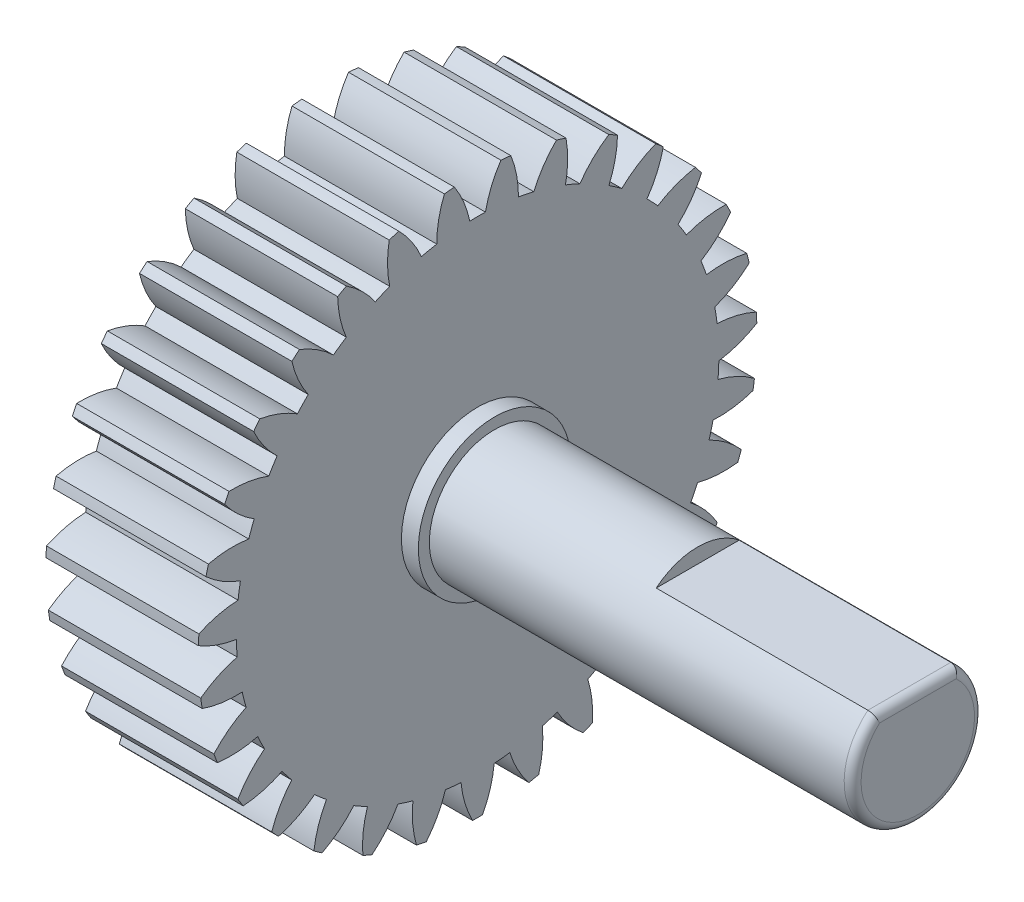
from build123d import *

# Parameters (mm, degrees)
BASPROSKE_W              = 9
BASPROSKE_H              = 16.5
TOOTHCUT_DEPTH           = 26.009998001
TEETHCUTS_COUNT          = 31
TEETHCUTS_ANGLE          = 348.387096774
BORSKE_R                 = 2
BORE_DEPTH               = 50.0000508
SKETCH2_R                = 4.5
BOSS_EXTRUDE1_DEPTH      = 1
BOSS_EXTRUDE2_DEPTH      = 26
BOSS_EXTRUDE2_DEPTH_BACK = 9
BOSS_EXTRUDE3_DEPTH      = 13
BOSS_EXTRUDE3_DEPTH_BACK = 9
FILLET1_R                = 0.5


with BuildPart() as part:
    # BasProSke → Base-Revolve (revolve)
    with BuildSketch(Plane(origin=(0, 0, 0), x_dir=(1, 0, 0), z_dir=(0, 1, 0))):
        with Locations((4.5, 8.25)):
            Rectangle(BASPROSKE_W, BASPROSKE_H)
    revolve(axis=Axis((-10, 0, 0), (1, 0, 0)))

    # TooCutSke → ToothCut (cut, through all)
    with BuildSketch(Plane(origin=(0, 0, 0), x_dir=(0, 0, -1), z_dir=(1, 0, 0))):
        with BuildLine():
            ThreePointArc((0.464153838, 14.241438207), (0, 14.249), (-0.464153838, 14.241438207))
            ThreePointArc((-0.464153838, 14.241438207), (-0.818831014, 15.399587018), (-1.391915479, 16.466675938))
            ThreePointArc((-1.391915479, 16.466675938), (0, 16.5254), (1.391915479, 16.466675938))
            ThreePointArc((1.391915479, 16.466675938), (0.818831014, 15.399587018), (0.464153838, 14.241438207))
        make_face()
    toothcut = extrude(amount=TOOTHCUT_DEPTH, mode=Mode.SUBTRACT)

    # TeethCuts: ToothCut ×31 about axis
    teethcuts_axis = Axis((-10, 0, 0), (1, 0, 0))
    for i in range(1, TEETHCUTS_COUNT):
        add(toothcut.rotate(teethcuts_axis, i * TEETHCUTS_ANGLE / (TEETHCUTS_COUNT - 1)), mode=Mode.SUBTRACT)

    # BorSke → Bore (cut, symmetric)
    with BuildSketch(Plane(origin=(0, 0, 0), x_dir=(0, 0, -1), z_dir=(1, 0, 0))):
        Circle(BORSKE_R)
    extrude(amount=BORE_DEPTH, both=True, mode=Mode.SUBTRACT)

    # Sketch2 → Boss-Extrude1 (add)
    with BuildSketch(Plane(origin=(9, 0, 0), x_dir=(0, 0, -1), z_dir=(1, 0, 0))):
        Circle(SKETCH2_R)
        with BuildLine():
            ThreePointArc((3.85, 0), (-1.641645516, -3.48245603), (-2.45, 2.969848481))
            ThreePointArc((-2.45, 2.969848481), (0, 3.85), (2.45, 2.969848481))
            ThreePointArc((2.45, 2.969848481), (3.48245603, 1.641645516), (3.85, 0))
        make_face(mode=Mode.SUBTRACT)
    extrude(amount=BOSS_EXTRUDE1_DEPTH)

    # Sketch2_3 → Boss-Extrude2 (add, two sides: drawn at the far end of the back side and taken through both)
    with BuildSketch(Plane(origin=(9, 0, 0), x_dir=(0, 0, -1), z_dir=(1, 0, 0)).offset(-BOSS_EXTRUDE2_DEPTH_BACK)):
        with BuildLine():
            Line((2.45, 2.969848481), (-2.45, 2.969848481))
            ThreePointArc((-2.45, 2.969848481), (-1.641645516, -3.48245603), (3.85, 0))
            ThreePointArc((3.85, 0), (3.48245603, 1.641645516), (2.45, 2.969848481))
        make_face()
    extrude(amount=BOSS_EXTRUDE2_DEPTH + BOSS_EXTRUDE2_DEPTH_BACK)

    # Sketch2_4 → Boss-Extrude3 (add, two sides: drawn at the far end of the back side and taken through both)
    with BuildSketch(Plane(origin=(9, 0, 0), x_dir=(0, 0, -1), z_dir=(1, 0, 0)).offset(-BOSS_EXTRUDE3_DEPTH_BACK)):
        with BuildLine():
            ThreePointArc((2.45, 2.969848481), (0, 3.85), (-2.45, 2.969848481))
            Line((-2.45, 2.969848481), (2.45, 2.969848481))
        make_face()
    extrude(amount=BOSS_EXTRUDE3_DEPTH + BOSS_EXTRUDE3_DEPTH_BACK)

    # Fillet1
    fillet1_edges = [part.edges().sort_by_distance(p)[0] for p in [
        (35, 2.969848481, 0),
        (35, -3.85, 0),
    ]]
    fillet(fillet1_edges, radius=FILLET1_R)


solid = part.part
